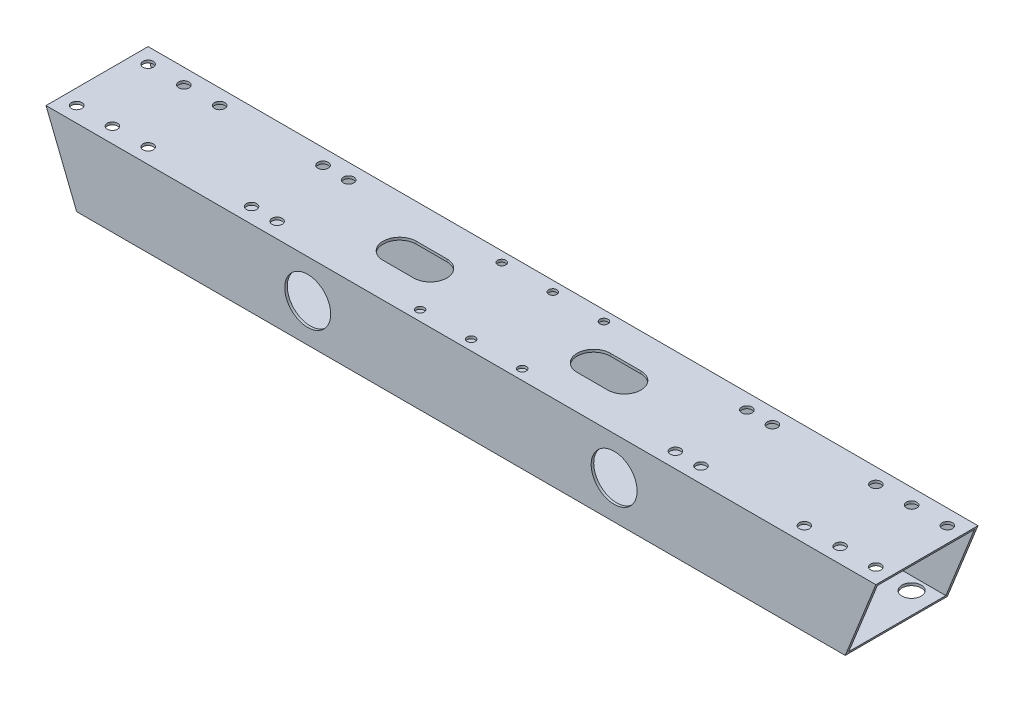
from build123d import *

# Parameters (mm, degrees)
SKETCH_1_W          = 40
SKETCH_1_H          = 30
SKETCH_1_W_2        = 38
SKETCH_1_H_2        = 28
EXTRUDE_1_DEPTH     = 325
SKETCH_2_R          = 2.025
CUT_EXTRUDE_1_DEPTH = 31
SKETCH_3_R          = 2.025
CUT_EXTRUDE_2_DEPTH = 31
SKETCH_4_R          = 1.6
CUT_EXTRUDE_3_DEPTH = 31
CUT_EXTRUDE_4_DEPTH = 41
CUT_EXTRUDE_5_REACH = 32
SKETCH_6_R          = 3.75
CUT_EXTRUDE_6_REACH = 32
SKETCH_7_R          = 3.75
CUT_EXTRUDE_7_REACH = 42
SKETCH_8_R          = 9
CUT_EXTRUDE_8_REACH = 32


with BuildPart() as part:
    # 草图1 → 凸台-拉伸1 (new body)
    with BuildSketch(Plane(origin=(0, 0, 0), x_dir=(0, 0, -1), z_dir=(1, 0, 0))):
        Rectangle(SKETCH_1_W, SKETCH_1_H)
        Rectangle(SKETCH_1_W_2, SKETCH_1_H_2, mode=Mode.SUBTRACT)
    extrude(amount=EXTRUDE_1_DEPTH)

    # 草图2 → 切除-拉伸1 (cut, through all)
    with BuildSketch(Plane.XZ.offset(15)):
        with Locations((74.5, 14)):
            Circle(SKETCH_2_R)
        with Locations((84.5, 14)):
            Circle(SKETCH_2_R)
        with Locations((84.5, -14)):
            Circle(SKETCH_2_R)
        with Locations((74.5, -14)):
            Circle(SKETCH_2_R)
        with Locations((250.5, -14)):
            Circle(SKETCH_2_R)
        with Locations((240.5, -14)):
            Circle(SKETCH_2_R)
        with Locations((240.5, 14)):
            Circle(SKETCH_2_R)
        with Locations((250.5, 14)):
            Circle(SKETCH_2_R)
    extrude(amount=-CUT_EXTRUDE_1_DEPTH, mode=Mode.SUBTRACT)

    # 草图3 → 切除-拉伸2 (cut, through all)
    with BuildSketch(Plane.XZ.offset(15)):
        with Locations((291, 14)):
            Circle(SKETCH_3_R)
        with Locations((305, 14)):
            Circle(SKETCH_3_R)
        with Locations((319, 14)):
            Circle(SKETCH_3_R)
        with Locations((319, -14)):
            Circle(SKETCH_3_R)
        with Locations((305, -14)):
            Circle(SKETCH_3_R)
        with Locations((291, -14)):
            Circle(SKETCH_3_R)
        with Locations((34, -14)):
            Circle(SKETCH_3_R)
        with Locations((20, -14)):
            Circle(SKETCH_3_R)
        with Locations((6, -14)):
            Circle(SKETCH_3_R)
        with Locations((6, 14)):
            Circle(SKETCH_3_R)
        with Locations((20, 14)):
            Circle(SKETCH_3_R)
        with Locations((34, 14)):
            Circle(SKETCH_3_R)
    extrude(amount=-CUT_EXTRUDE_2_DEPTH, mode=Mode.SUBTRACT)

    # 草图4 → 切除-拉伸3 (cut, through all)
    with BuildSketch(Plane.XZ.offset(15)):
        with Locations((142.5, 16)):
            Circle(SKETCH_4_R)
        with Locations((162.5, 16)):
            Circle(SKETCH_4_R)
        with Locations((182.5, 16)):
            Circle(SKETCH_4_R)
        with Locations((182.5, -16)):
            Circle(SKETCH_4_R)
        with Locations((162.5, -16)):
            Circle(SKETCH_4_R)
        with Locations((142.5, -16)):
            Circle(SKETCH_4_R)
    extrude(amount=-CUT_EXTRUDE_3_DEPTH, mode=Mode.SUBTRACT)

    # 草图5 → 切除-拉伸4 (cut, through all)
    with BuildSketch(Plane.XY.offset(20)):
        Polygon((0, 15), (12, -15), (0, -15), align=None)
        Polygon((313, -15), (325, -15), (325, 15), align=None)
    extrude(amount=-CUT_EXTRUDE_4_DEPTH, mode=Mode.SUBTRACT)

    # 草图6 → 切除-拉伸5 (cut, up to next)
    with BuildSketch(Plane.XZ.offset(15), mode=Mode.PRIVATE) as cut_extrude_5_sk1:
        with Locations((74.5, 14)):
            Circle(SKETCH_6_R)
    cut_extrude_5_tool1 = extrude(cut_extrude_5_sk1.sketch, amount=-CUT_EXTRUDE_5_REACH, mode=Mode.PRIVATE) & part.part
    add(cut_extrude_5_tool1.solids().sort_by_distance((74.5, -15, 14))[0], mode=Mode.SUBTRACT)
    # 草图6 → 切除-拉伸5 (cut, up to next)
    with BuildSketch(Plane.XZ.offset(15), mode=Mode.PRIVATE) as cut_extrude_5_sk2:
        with Locations((84.5, 14)):
            Circle(SKETCH_6_R)
    cut_extrude_5_tool2 = extrude(cut_extrude_5_sk2.sketch, amount=-CUT_EXTRUDE_5_REACH, mode=Mode.PRIVATE) & part.part
    add(cut_extrude_5_tool2.solids().sort_by_distance((84.5, -15, 14))[0], mode=Mode.SUBTRACT)
    # 草图6 → 切除-拉伸5 (cut, up to next)
    with BuildSketch(Plane.XZ.offset(15), mode=Mode.PRIVATE) as cut_extrude_5_sk3:
        with Locations((84.5, -14)):
            Circle(SKETCH_6_R)
    cut_extrude_5_tool3 = extrude(cut_extrude_5_sk3.sketch, amount=-CUT_EXTRUDE_5_REACH, mode=Mode.PRIVATE) & part.part
    add(cut_extrude_5_tool3.solids().sort_by_distance((84.5, -15, -14))[0], mode=Mode.SUBTRACT)
    # 草图6 → 切除-拉伸5 (cut, up to next)
    with BuildSketch(Plane.XZ.offset(15), mode=Mode.PRIVATE) as cut_extrude_5_sk4:
        with Locations((74.5, -14)):
            Circle(SKETCH_6_R)
    cut_extrude_5_tool4 = extrude(cut_extrude_5_sk4.sketch, amount=-CUT_EXTRUDE_5_REACH, mode=Mode.PRIVATE) & part.part
    add(cut_extrude_5_tool4.solids().sort_by_distance((74.5, -15, -14))[0], mode=Mode.SUBTRACT)
    # 草图6 → 切除-拉伸5 (cut, up to next)
    with BuildSketch(Plane.XZ.offset(15), mode=Mode.PRIVATE) as cut_extrude_5_sk5:
        with Locations((250.5, -14)):
            Circle(SKETCH_6_R)
    cut_extrude_5_tool5 = extrude(cut_extrude_5_sk5.sketch, amount=-CUT_EXTRUDE_5_REACH, mode=Mode.PRIVATE) & part.part
    add(cut_extrude_5_tool5.solids().sort_by_distance((250.5, -15, -14))[0], mode=Mode.SUBTRACT)
    # 草图6 → 切除-拉伸5 (cut, up to next)
    with BuildSketch(Plane.XZ.offset(15), mode=Mode.PRIVATE) as cut_extrude_5_sk6:
        with Locations((240.5, -14)):
            Circle(SKETCH_6_R)
    cut_extrude_5_tool6 = extrude(cut_extrude_5_sk6.sketch, amount=-CUT_EXTRUDE_5_REACH, mode=Mode.PRIVATE) & part.part
    add(cut_extrude_5_tool6.solids().sort_by_distance((240.5, -15, -14))[0], mode=Mode.SUBTRACT)
    # 草图6 → 切除-拉伸5 (cut, up to next)
    with BuildSketch(Plane.XZ.offset(15), mode=Mode.PRIVATE) as cut_extrude_5_sk7:
        with Locations((240.5, 14)):
            Circle(SKETCH_6_R)
    cut_extrude_5_tool7 = extrude(cut_extrude_5_sk7.sketch, amount=-CUT_EXTRUDE_5_REACH, mode=Mode.PRIVATE) & part.part
    add(cut_extrude_5_tool7.solids().sort_by_distance((240.5, -15, 14))[0], mode=Mode.SUBTRACT)
    # 草图6 → 切除-拉伸5 (cut, up to next)
    with BuildSketch(Plane.XZ.offset(15), mode=Mode.PRIVATE) as cut_extrude_5_sk8:
        with Locations((250.5, 14)):
            Circle(SKETCH_6_R)
    cut_extrude_5_tool8 = extrude(cut_extrude_5_sk8.sketch, amount=-CUT_EXTRUDE_5_REACH, mode=Mode.PRIVATE) & part.part
    add(cut_extrude_5_tool8.solids().sort_by_distance((250.5, -15, 14))[0], mode=Mode.SUBTRACT)

    # 草图7 → 切除-拉伸6 (cut, up to next)
    with BuildSketch(Plane.XZ.offset(15), mode=Mode.PRIVATE) as cut_extrude_6_sk1:
        with Locations((20, 14)):
            Circle(SKETCH_7_R)
    cut_extrude_6_tool1 = extrude(cut_extrude_6_sk1.sketch, amount=-CUT_EXTRUDE_6_REACH, mode=Mode.PRIVATE) & part.part
    add(cut_extrude_6_tool1.solids().sort_by_distance((20, -15, 14))[0], mode=Mode.SUBTRACT)
    # 草图7 → 切除-拉伸6 (cut, up to next)
    with BuildSketch(Plane.XZ.offset(15), mode=Mode.PRIVATE) as cut_extrude_6_sk2:
        with Locations((34, 14)):
            Circle(SKETCH_7_R)
    cut_extrude_6_tool2 = extrude(cut_extrude_6_sk2.sketch, amount=-CUT_EXTRUDE_6_REACH, mode=Mode.PRIVATE) & part.part
    add(cut_extrude_6_tool2.solids().sort_by_distance((34, -15, 14))[0], mode=Mode.SUBTRACT)
    # 草图7 → 切除-拉伸6 (cut, up to next)
    with BuildSketch(Plane.XZ.offset(15), mode=Mode.PRIVATE) as cut_extrude_6_sk3:
        with Locations((34, -14)):
            Circle(SKETCH_7_R)
    cut_extrude_6_tool3 = extrude(cut_extrude_6_sk3.sketch, amount=-CUT_EXTRUDE_6_REACH, mode=Mode.PRIVATE) & part.part
    add(cut_extrude_6_tool3.solids().sort_by_distance((34, -15, -14))[0], mode=Mode.SUBTRACT)
    # 草图7 → 切除-拉伸6 (cut, up to next)
    with BuildSketch(Plane.XZ.offset(15), mode=Mode.PRIVATE) as cut_extrude_6_sk4:
        with Locations((20, -14)):
            Circle(SKETCH_7_R)
    cut_extrude_6_tool4 = extrude(cut_extrude_6_sk4.sketch, amount=-CUT_EXTRUDE_6_REACH, mode=Mode.PRIVATE) & part.part
    add(cut_extrude_6_tool4.solids().sort_by_distance((20, -15, -14))[0], mode=Mode.SUBTRACT)
    # 草图7 → 切除-拉伸6 (cut, up to next)
    with BuildSketch(Plane.XZ.offset(15), mode=Mode.PRIVATE) as cut_extrude_6_sk5:
        with Locations((305, -14)):
            Circle(SKETCH_7_R)
    cut_extrude_6_tool5 = extrude(cut_extrude_6_sk5.sketch, amount=-CUT_EXTRUDE_6_REACH, mode=Mode.PRIVATE) & part.part
    add(cut_extrude_6_tool5.solids().sort_by_distance((305, -15, -14))[0], mode=Mode.SUBTRACT)
    # 草图7 → 切除-拉伸6 (cut, up to next)
    with BuildSketch(Plane.XZ.offset(15), mode=Mode.PRIVATE) as cut_extrude_6_sk6:
        with Locations((291, -14)):
            Circle(SKETCH_7_R)
    cut_extrude_6_tool6 = extrude(cut_extrude_6_sk6.sketch, amount=-CUT_EXTRUDE_6_REACH, mode=Mode.PRIVATE) & part.part
    add(cut_extrude_6_tool6.solids().sort_by_distance((291, -15, -14))[0], mode=Mode.SUBTRACT)
    # 草图7 → 切除-拉伸6 (cut, up to next)
    with BuildSketch(Plane.XZ.offset(15), mode=Mode.PRIVATE) as cut_extrude_6_sk7:
        with Locations((291, 14)):
            Circle(SKETCH_7_R)
    cut_extrude_6_tool7 = extrude(cut_extrude_6_sk7.sketch, amount=-CUT_EXTRUDE_6_REACH, mode=Mode.PRIVATE) & part.part
    add(cut_extrude_6_tool7.solids().sort_by_distance((291, -15, 14))[0], mode=Mode.SUBTRACT)
    # 草图7 → 切除-拉伸6 (cut, up to next)
    with BuildSketch(Plane.XZ.offset(15), mode=Mode.PRIVATE) as cut_extrude_6_sk8:
        with Locations((305, 14)):
            Circle(SKETCH_7_R)
    cut_extrude_6_tool8 = extrude(cut_extrude_6_sk8.sketch, amount=-CUT_EXTRUDE_6_REACH, mode=Mode.PRIVATE) & part.part
    add(cut_extrude_6_tool8.solids().sort_by_distance((305, -15, 14))[0], mode=Mode.SUBTRACT)

    # 草图8 → 切除-拉伸7 (cut, up to next)
    with BuildSketch(Plane.XY.offset(20), mode=Mode.PRIVATE) as cut_extrude_7_sk1:
        with Locations((102.5, 0)):
            Circle(SKETCH_8_R)
    cut_extrude_7_tool1 = extrude(cut_extrude_7_sk1.sketch, amount=-CUT_EXTRUDE_7_REACH, mode=Mode.PRIVATE) & part.part
    add(cut_extrude_7_tool1.solids().sort_by_distance((102.5, 0, 20))[0], mode=Mode.SUBTRACT)
    # 草图8 → 切除-拉伸7 (cut, up to next)
    with BuildSketch(Plane.XY.offset(20), mode=Mode.PRIVATE) as cut_extrude_7_sk2:
        with Locations((222.5, 0)):
            Circle(SKETCH_8_R)
    cut_extrude_7_tool2 = extrude(cut_extrude_7_sk2.sketch, amount=-CUT_EXTRUDE_7_REACH, mode=Mode.PRIVATE) & part.part
    add(cut_extrude_7_tool2.solids().sort_by_distance((222.5, 0, 20))[0], mode=Mode.SUBTRACT)

    # 草图9 → 切除-拉伸8 (cut, up to next)
    with BuildSketch(Plane(origin=(0, 15, 0), x_dir=(1, 0, 0), z_dir=(0, 1, 0)), mode=Mode.PRIVATE) as cut_extrude_8_sk1:
        with BuildLine():
            Line((118.5, 6.5), (130.5, 6.5))
            ThreePointArc((130.5, 6.5), (137, 0), (130.5, -6.5))
            Line((130.5, -6.5), (118.5, -6.5))
            ThreePointArc((118.5, -6.5), (112, 0), (118.5, 6.5))
        make_face()
    cut_extrude_8_tool1 = extrude(cut_extrude_8_sk1.sketch, amount=-CUT_EXTRUDE_8_REACH, mode=Mode.PRIVATE) & part.part
    add(cut_extrude_8_tool1.solids().sort_by_distance((124.5, 15, 0))[0], mode=Mode.SUBTRACT)
    # 草图9 → 切除-拉伸8 (cut, up to next)
    with BuildSketch(Plane(origin=(0, 15, 0), x_dir=(1, 0, 0), z_dir=(0, 1, 0)), mode=Mode.PRIVATE) as cut_extrude_8_sk2:
        with BuildLine():
            Line((206.5, 6.5), (194.5, 6.5))
            ThreePointArc((194.5, 6.5), (188, 0), (194.5, -6.5))
            Line((194.5, -6.5), (206.5, -6.5))
            ThreePointArc((206.5, -6.5), (213, 0), (206.5, 6.5))
        make_face()
    cut_extrude_8_tool2 = extrude(cut_extrude_8_sk2.sketch, amount=-CUT_EXTRUDE_8_REACH, mode=Mode.PRIVATE) & part.part
    add(cut_extrude_8_tool2.solids().sort_by_distance((200.5, 15, 0))[0], mode=Mode.SUBTRACT)


solid = part.part
